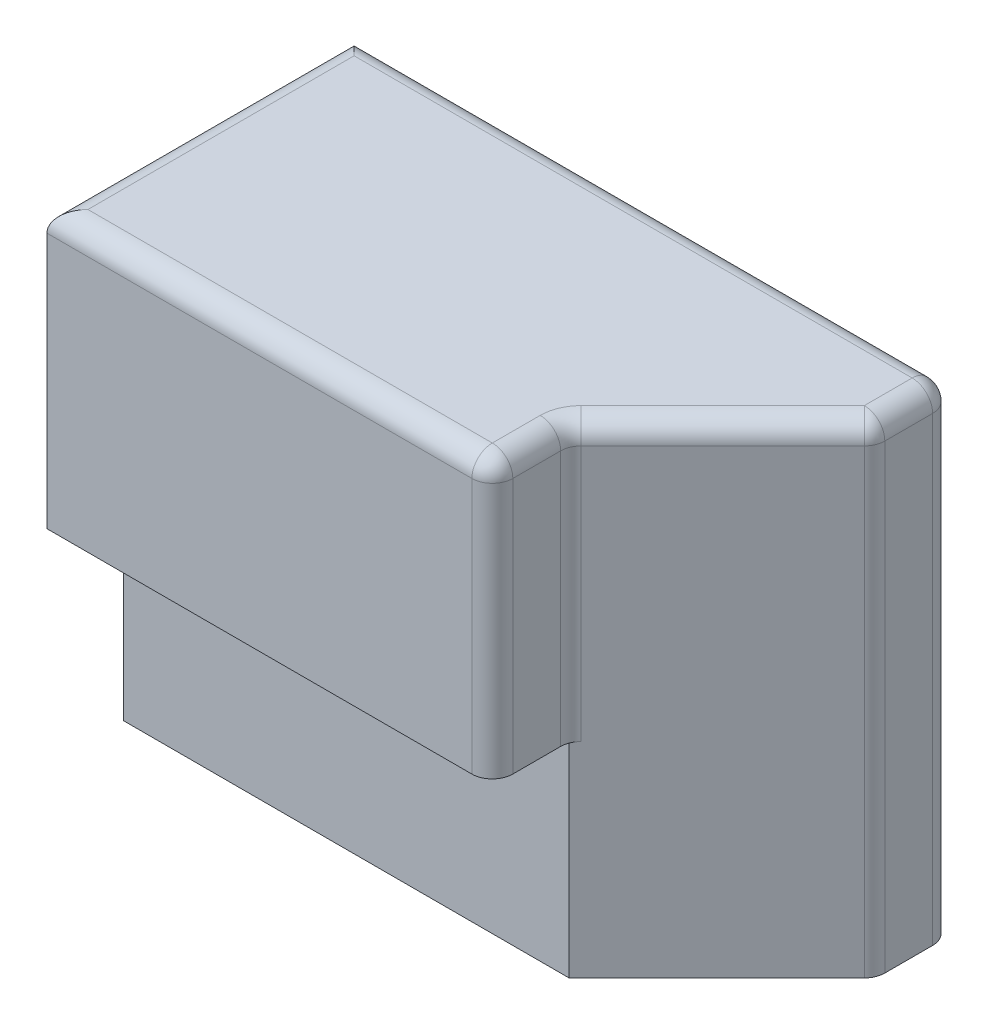
from build123d import *

# Parameters (mm, degrees)
SKETCH2_W           = 14.859
SKETCH2_H           = 11.938
BOSS_EXTRUDE1_DEPTH = 7.62
CUT_EXTRUDE2_DEPTH  = 2.794
CUT_EXTRUDE3_DEPTH  = 1.905
CUT_EXTRUDE4_DEPTH  = 12.938
FILLET1_R           = 0.508
SKETCH7_R           = 0.635
CUT_EXTRUDE13_DEPTH = 1.905


with BuildPart() as part:
    # Sketch2 → Boss-Extrude1 (new body)
    with BuildSketch(Plane.XY):
        with Locations((7.4295, 5.969)):
            Rectangle(SKETCH2_W, SKETCH2_H)
    extrude(amount=BOSS_EXTRUDE1_DEPTH)

    # Sketch4 → Cut-Extrude2 (cut)
    with BuildSketch(Plane(origin=(0, 0, 0), x_dir=(-1, 0, 0), z_dir=(0, 0, -1))):
        with BuildLine():
            Line((0, 0), (-10.16, 0))
            Line((-10.16, 0), (-10.16, 8.255))
            ThreePointArc((-10.16, 8.255), (-9.602038418, 9.602038418), (-8.255, 10.16))
            Line((-8.255, 10.16), (0, 10.16))
            Line((0, 10.16), (0, 0))
        make_face()
    extrude(amount=-CUT_EXTRUDE2_DEPTH, mode=Mode.SUBTRACT)

    # Sketch5 → Cut-Extrude3 (cut)
    with BuildSketch(Plane.XY.offset(7.62)):
        Polygon((14.859, 11.938), (11.049, 11.938), (11.049, 5.08), (0, 5.08), (0, 0), (14.859, 0), align=None)
    extrude(amount=-CUT_EXTRUDE3_DEPTH, mode=Mode.SUBTRACT)

    # Sketch6 → Cut-Extrude4 (cut, through all)
    with BuildSketch(Plane(origin=(0, 11.938, 0), x_dir=(1, 0, 0), z_dir=(0, 1, 0))):
        Polygon((14.859, -1.905), (11.049, -5.715), (14.859, -5.715), align=None)
    extrude(amount=-CUT_EXTRUDE4_DEPTH, mode=Mode.SUBTRACT)

    # Fillet1
    fillet1_edges = [part.edges().sort_by_distance(p)[0] for p in [
        (5.5245, 11.938, 7.62),
        (11.049, 11.938, 6.6675),
        (11.049, 8.509, 5.715),
        (11.049, 8.509, 7.62),
        (7.4295, 11.938, 0),
        (14.859, 11.938, 0.9525),
        (14.859, 5.969, 0),
        (12.954, 11.938, 3.81),
        (14.859, 5.969, 1.905),
        (0, 11.938, 3.81),
    ]]
    fillet(fillet1_edges, radius=FILLET1_R)

    # Sketch7 → Cut-Extrude13 (cut)
    with BuildSketch(Plane(origin=(0, 0, 2.794), x_dir=(-1, 0, 0), z_dir=(0, 0, -1))):
        with Locations((-3.81, 3.81)):
            Circle(SKETCH7_R)
    extrude(amount=-CUT_EXTRUDE13_DEPTH, mode=Mode.SUBTRACT)


solid = part.part
